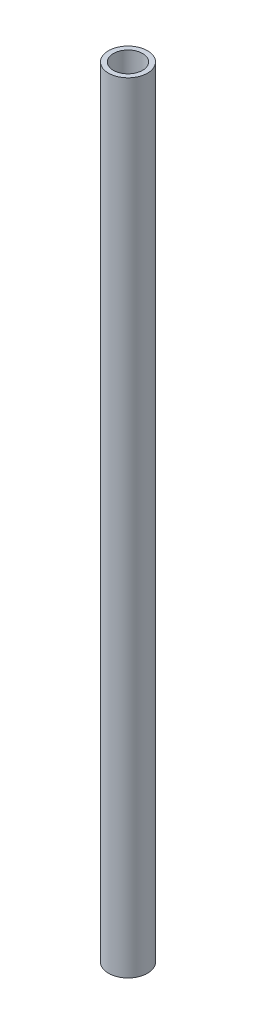
from build123d import *

# Parameters (mm, degrees)
SKETCH1_R           = 4
SKETCH1_R_2         = 3
BOSS_EXTRUDE1_DEPTH = 160


with BuildPart() as part:
    # Sketch1 → Boss-Extrude1 (new body)
    with BuildSketch(Plane(origin=(0, 0, 0), x_dir=(1, 0, 0), z_dir=(0, 1, 0))):
        Circle(SKETCH1_R)
        Circle(SKETCH1_R_2, mode=Mode.SUBTRACT)
    extrude(amount=BOSS_EXTRUDE1_DEPTH)


solid = part.part
